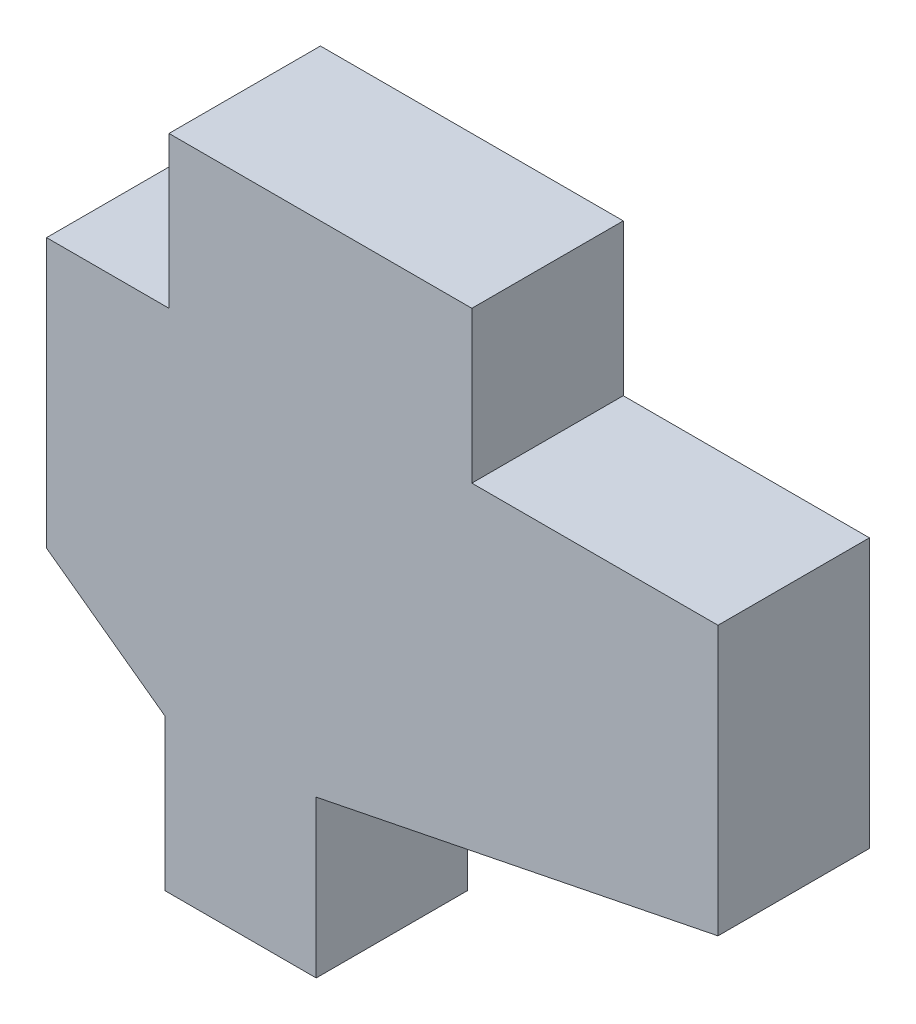
from build123d import *

# Parameters (mm, degrees)
BOSS_EXTRUDE1_DEPTH = 1.524


with BuildPart() as part:
    # Sketch1 → Boss-Extrude1 (new body)
    with BuildSketch(Plane.XY):
        Polygon((-75.146741226, -1.524), (-75.146741226, 0), (-72.098741226, 0), (-72.098741226, -1.524), (-69.621457776, -1.524), (-69.621457776, -4.231372842), (-73.665237024, -5.043705171), (-73.665237024, -6.620374737), (-75.189237024, -6.620374737), (-75.189237024, -5.096374737), (-76.378564211, -4.231372842), (-76.378564211, -1.524), align=None)
    extrude(amount=BOSS_EXTRUDE1_DEPTH)


solid = part.part
